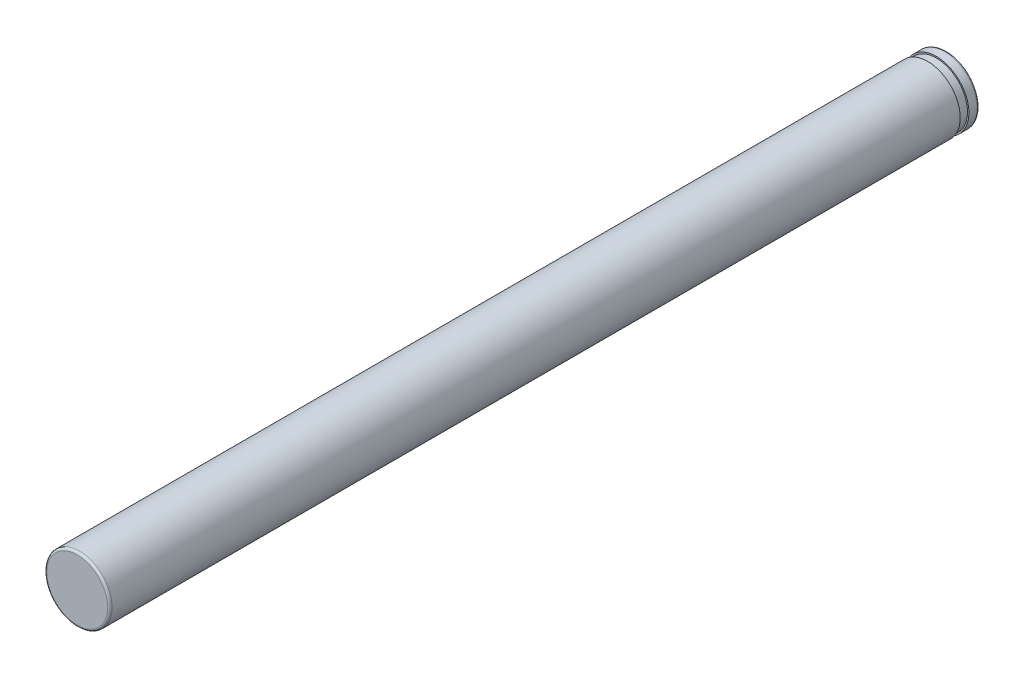
from build123d import *

# Parameters (mm, degrees)
SKETCH1_R           = 1.5
BOSS_EXTRUDE1_DEPTH = 40
FILLET1_R           = 0.1
FILLET2_R           = 0.1
SKETCH2_W           = 0.148162506
SKETCH2_H           = 0.4


with BuildPart() as part:
    # Sketch1 → Boss-Extrude1 (new body)
    with BuildSketch(Plane.XY):
        Circle(SKETCH1_R)
    extrude(amount=BOSS_EXTRUDE1_DEPTH)

    # Fillet1
    fillet1_edges = [part.edges().sort_by_distance(p)[0] for p in [
        (-1.5, 0, 40),
    ]]
    fillet(fillet1_edges, radius=FILLET1_R)

    # Fillet2
    fillet2_edges = [part.edges().sort_by_distance(p)[0] for p in [
        (-1.5, 0, 0),
    ]]
    fillet(fillet2_edges, radius=FILLET2_R)

    # Sketch2 → Cut-Revolve1 (revolve, cut)
    with BuildSketch(Plane(origin=(0, 0, 0), x_dir=(1, 0, 0), z_dir=(0, 1, 0))):
        with Locations((-1.508482483, -0.675553033)):
            Rectangle(SKETCH2_W, SKETCH2_H)
    revolve(axis=Axis((0, 0, 0), (0, 0, 1)), mode=Mode.SUBTRACT)


solid = part.part
